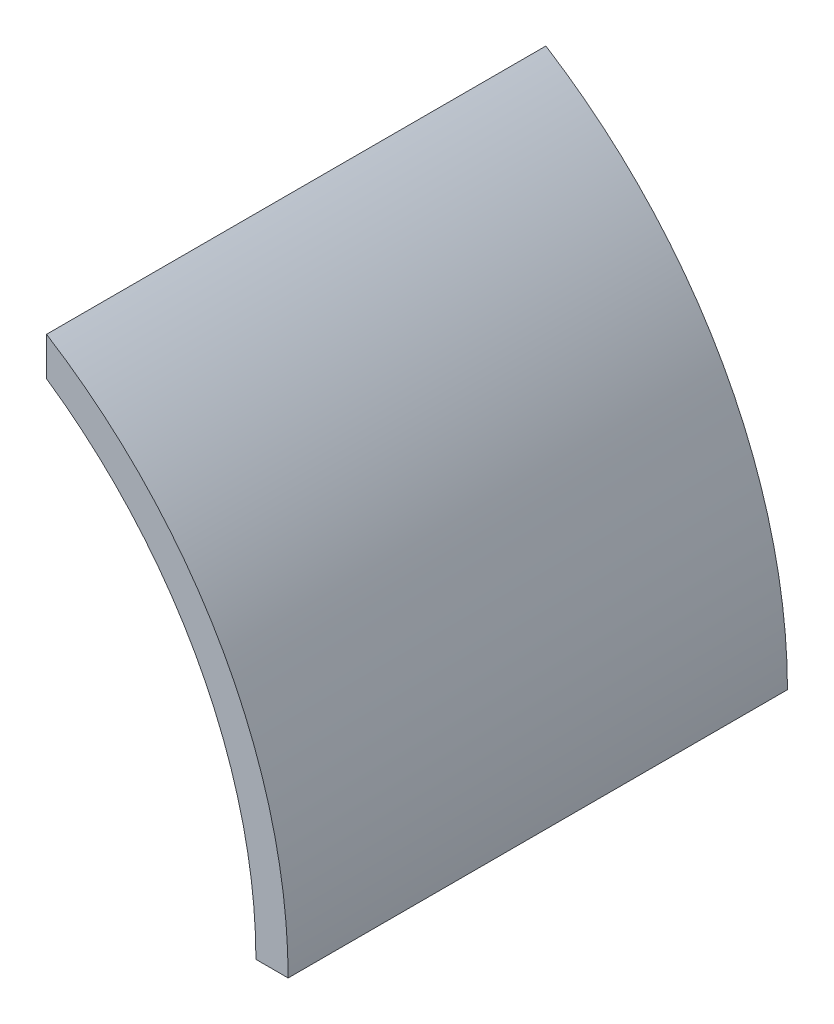
from build123d import *

# Parameters (mm, degrees)
INNER_RING_RIGHT_SIDE_DEPTH = 155


with BuildPart() as part:
    # Sketch2 → Inner Ring - Right Side (new body)
    with BuildSketch(Plane.XY):
        with BuildLine():
            Line((85, 135.554417117), (85, 123.592070943))
            ThreePointArc((85, 123.592070943), (132.759180474, 69.821200219), (150, 0))
            Line((150, 0), (160, 0))
            ThreePointArc((160, 0), (140, 77.459666924), (85, 135.554417117))
        make_face()
    extrude(amount=INNER_RING_RIGHT_SIDE_DEPTH)


solid = part.part
